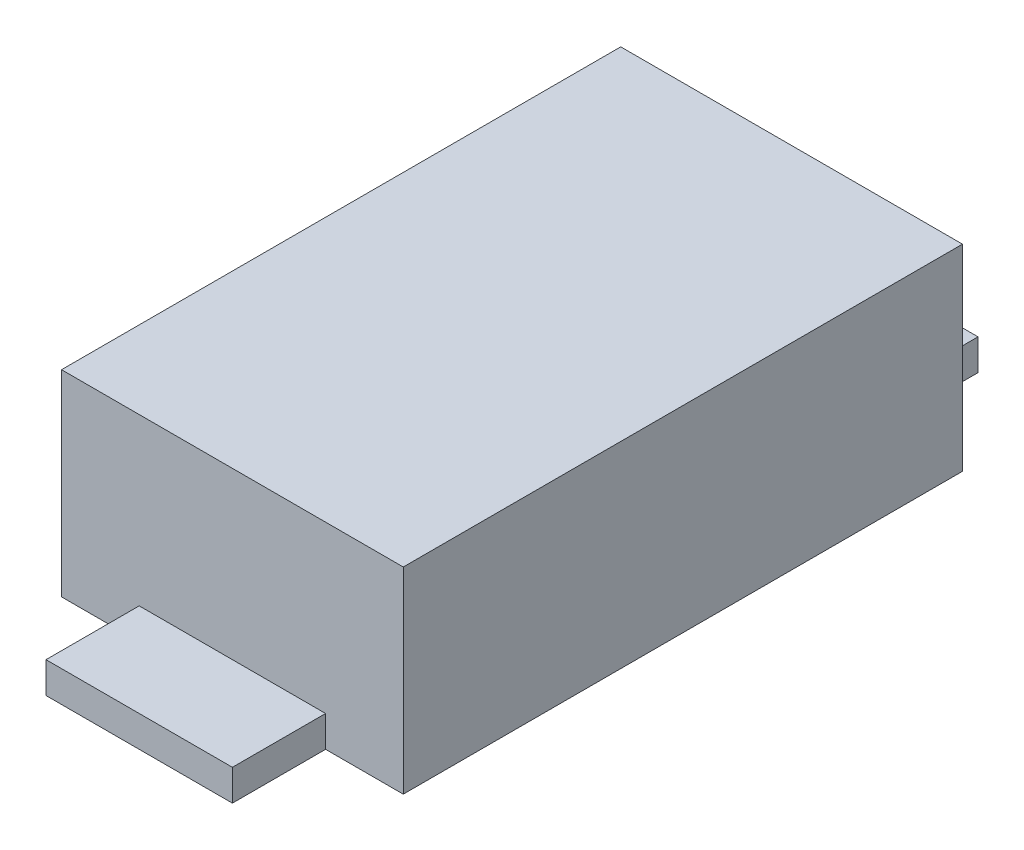
from build123d import *

# Parameters (mm, degrees)
BASES_W    = 1.65
BASES_H    = 2.7
BASE_DEPTH = 0.95
LEGS_W     = 0.9
LEGS_H     = 0.45
LEG_DEPTH  = 0.15


with BuildPart() as part:
    # BaseS → Base (new body)
    with BuildSketch(Plane(origin=(0, 0, 0), x_dir=(1, 0, 0), z_dir=(0, 1, 0))):
        Rectangle(BASES_W, BASES_H)
    extrude(amount=BASE_DEPTH)

    # LegS → Leg (add)
    with BuildSketch(Plane(origin=(0, 0, 0), x_dir=(1, 0, 0), z_dir=(0, 1, 0))):
        with Locations((0, 1.575)):
            Rectangle(LEGS_W, LEGS_H)
    leg = extrude(amount=LEG_DEPTH)

    # LVM: Leg across plane
    add(leg.mirror(Plane.XY))


solid = part.part
